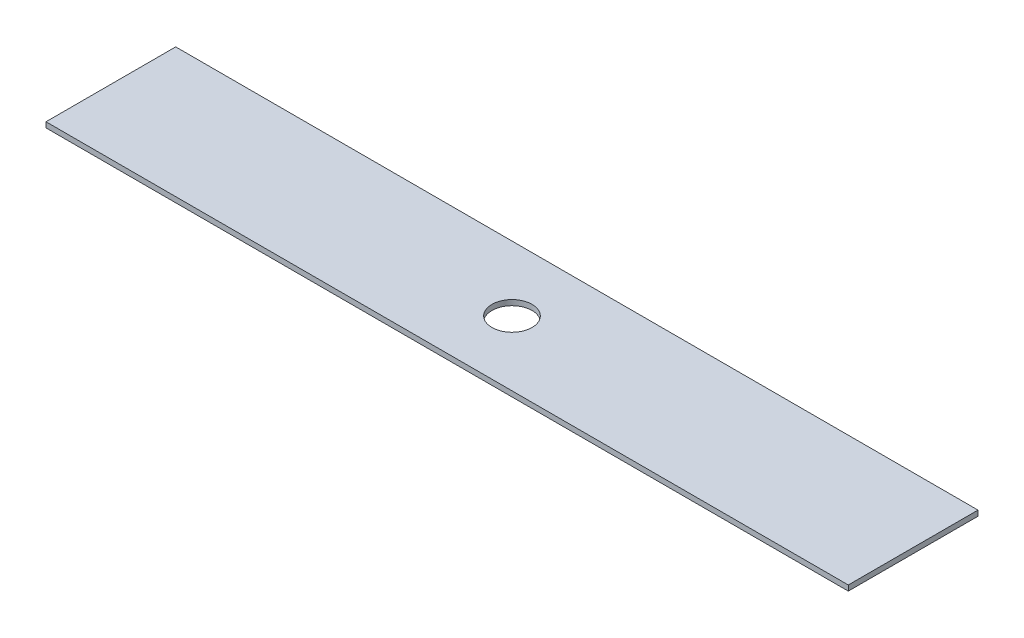
from build123d import *

# Parameters (mm, degrees)
SKETCH1_W           = 300
SKETCH1_H           = 48.5
BOSS_EXTRUDE1_DEPTH = 2
SKETCH2_R           = 7.5
CUT_EXTRUDE1_DEPTH  = 2


with BuildPart() as part:
    # Sketch1 → Boss-Extrude1 (new body)
    with BuildSketch(Plane(origin=(0, 0, 0), x_dir=(1, 0, 0), z_dir=(0, 1, 0))):
        with Locations((47.447653354, -15.150578189)):
            Rectangle(SKETCH1_W, SKETCH1_H)
    extrude(amount=BOSS_EXTRUDE1_DEPTH)

    # Sketch2 → Cut-Extrude1 (cut)
    with BuildSketch(Plane(origin=(0, 2, 0), x_dir=(1, 0, 0), z_dir=(0, 1, 0))):
        with Locations((47.447653354, -15.150578189)):
            Circle(SKETCH2_R)
    extrude(amount=-CUT_EXTRUDE1_DEPTH, mode=Mode.SUBTRACT)


solid = part.part
